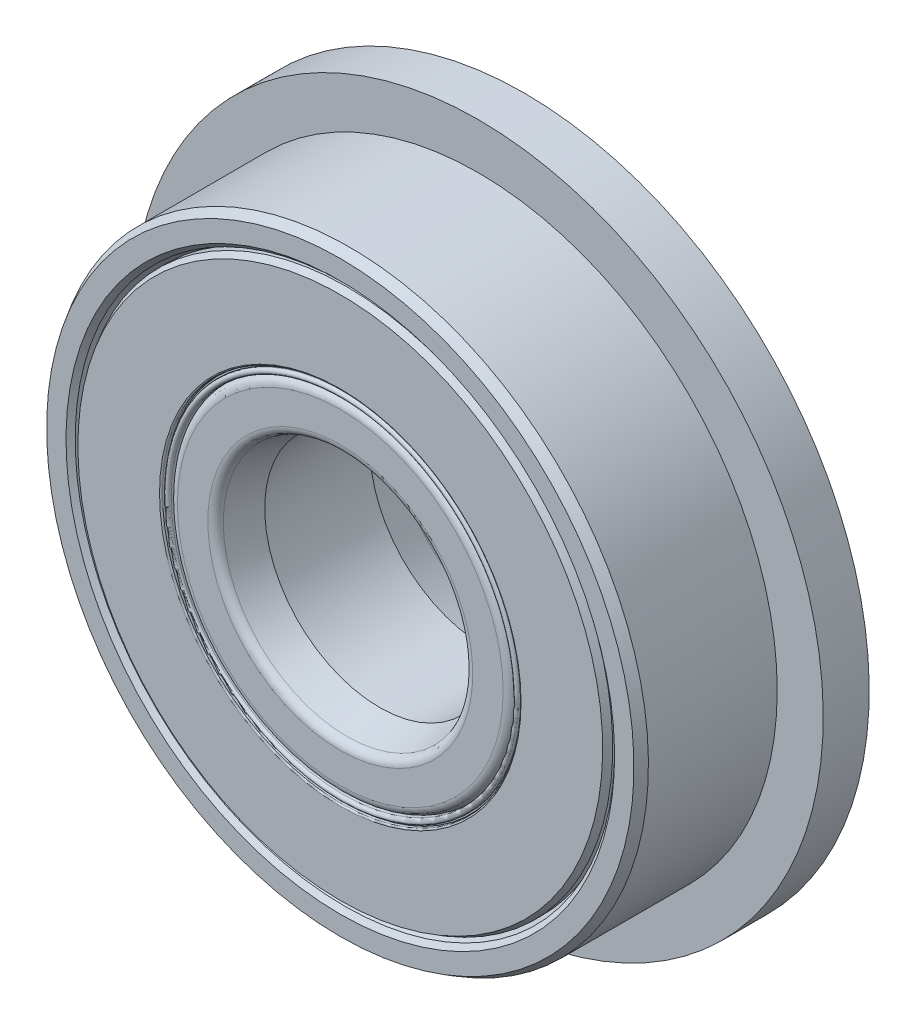
from build123d import *

# Parameters (mm, degrees)
SKETCH8_R           = 7.5
SKETCH8_R_2         = 6.384529946
BOSS_EXTRUDE1_DEPTH = 1


with BuildPart() as part:
    # Sketch3 → Revolve1 (revolve)
    with BuildSketch(Plane(origin=(0, 0, 0), x_dir=(0, 0, -1), z_dir=(1, 0, 0))):
        with BuildLine():
            Line((-1.682987285, 5.785), (-1.9, 5.863986169))
            Line((-1.9, 5.863986169), (-2, 5.963986169))
            Line((-2, 5.963986169), (-2, 6.384529946))
            Line((-2, 6.384529946), (-1.8, 6.5))
            Line((-1.8, 6.5), (1.8, 6.5))
            Line((1.8, 6.5), (2, 6.384529946))
            Line((2, 6.384529946), (2, 5.963986169))
            Line((2, 5.963986169), (1.9, 5.863986169))
            Line((1.9, 5.863986169), (1.682987285, 5.785))
            Line((1.682987285, 5.785), (1.096717324, 5.785))
            ThreePointArc((1.096717324, 5.785), (0, 6.261666667), (-1.096717324, 5.785))
            Line((-1.096717324, 5.785), (-1.682987285, 5.785))
        make_face()
    revolve(axis=Axis((0, 0, 2), (0, 0, -1)))

    # Sketch8 → Boss-Extrude1 (add)
    with BuildSketch(Plane(origin=(0, 0, -2), x_dir=(-1, 0, 0), z_dir=(0, 0, -1))):
        Circle(SKETCH8_R)
        Circle(SKETCH8_R_2, mode=Mode.SUBTRACT)
    extrude(amount=-BOSS_EXTRUDE1_DEPTH)


with BuildPart() as body_2:
    # Sketch4 → Revolve2 (revolve)
    with BuildSketch(Plane(origin=(0, 0, 0), x_dir=(0, 0, -1), z_dir=(1, 0, 0))):
        with BuildLine():
            Line((-1.143243478, 2.5), (-1.853888153, 2.690416667))
            ThreePointArc((-1.853888153, 2.690416667), (-1.959262951, 2.760825856), (-2, 2.880833333))
            Line((-2, 2.880833333), (-2, 3.541199494))
            ThreePointArc((-2, 3.541199494), (-1.942260835, 3.680594169), (-1.802866161, 3.738333333))
            Line((-1.802866161, 3.738333333), (-1.096717324, 3.738333333))
            ThreePointArc((-1.096717324, 3.738333333), (0, 3.261666667), (1.096717324, 3.738333333))
            Line((1.096717324, 3.738333333), (1.802866161, 3.738333333))
            ThreePointArc((1.802866161, 3.738333333), (1.942260835, 3.680594169), (2, 3.541199494))
            Line((2, 3.541199494), (2, 2.880833333))
            ThreePointArc((2, 2.880833333), (1.959262951, 2.760825856), (1.853888153, 2.690416667))
            Line((1.853888153, 2.690416667), (1.143243478, 2.5))
            Line((1.143243478, 2.5), (-1.143243478, 2.5))
        make_face()
    revolve(axis=Axis((0, 0, 2), (0, 0, -1)))


with BuildPart() as body_3:
    # Sketch6 → Revolve4 (revolve)
    with BuildSketch(Plane(origin=(0, 0, 0), x_dir=(0, 0, -1), z_dir=(1, 0, 0))):
        with BuildLine():
            Line((-1.861435935, 5.785), (-1.5, 5.785))
            Line((-1.5, 5.785), (-1.5, 3.898333333))
            Line((-1.5, 3.898333333), (-1.968, 3.898333333))
            ThreePointArc((-1.968, 3.898333333), (-1.990627417, 3.907705916), (-2, 3.930333333))
            Line((-2, 3.930333333), (-2, 5.705))
            Line((-2, 5.705), (-1.861435935, 5.785))
        make_face()
        with BuildLine():
            Line((1.968, 3.898333333), (1.5, 3.898333333))
            Line((1.5, 3.898333333), (1.5, 5.785))
            Line((1.5, 5.785), (1.861435935, 5.785))
            Line((1.861435935, 5.785), (2, 5.705))
            Line((2, 5.705), (2, 3.930333333))
            ThreePointArc((2, 3.930333333), (1.990627417, 3.907705916), (1.968, 3.898333333))
        make_face()
    revolve(axis=Axis((0, 0, 2), (0, 0, -1)))


with BuildPart() as body_4:
    # Sketch7 → Revolve5 (revolve)
    with BuildSketch(Plane(origin=(0, 0, 0), x_dir=(0, 0, -1), z_dir=(1, 0, 0))):
        with BuildLine():
            Line((-1.5, 3.898333333), (-1.878499547, 3.898333333))
            Line((-1.878499547, 3.898333333), (-1.917891857, 3.891387406))
            ThreePointArc((-1.917891857, 3.891387406), (-1.931590167, 3.873535421), (-1.915, 3.858333333))
            Line((-1.915, 3.858333333), (-1.94, 3.858333333))
            ThreePointArc((-1.94, 3.858333333), (-2, 3.798333333), (-1.94, 3.738333333))
            Line((-1.94, 3.738333333), (-1.5, 3.738333333))
            Line((-1.5, 3.738333333), (-1.5, 3.898333333))
        make_face()
    revolve(axis=Axis((0, 0, 2), (0, 0, -1)))


solid = Compound([part.part, body_2.part, body_3.part, body_4.part])
